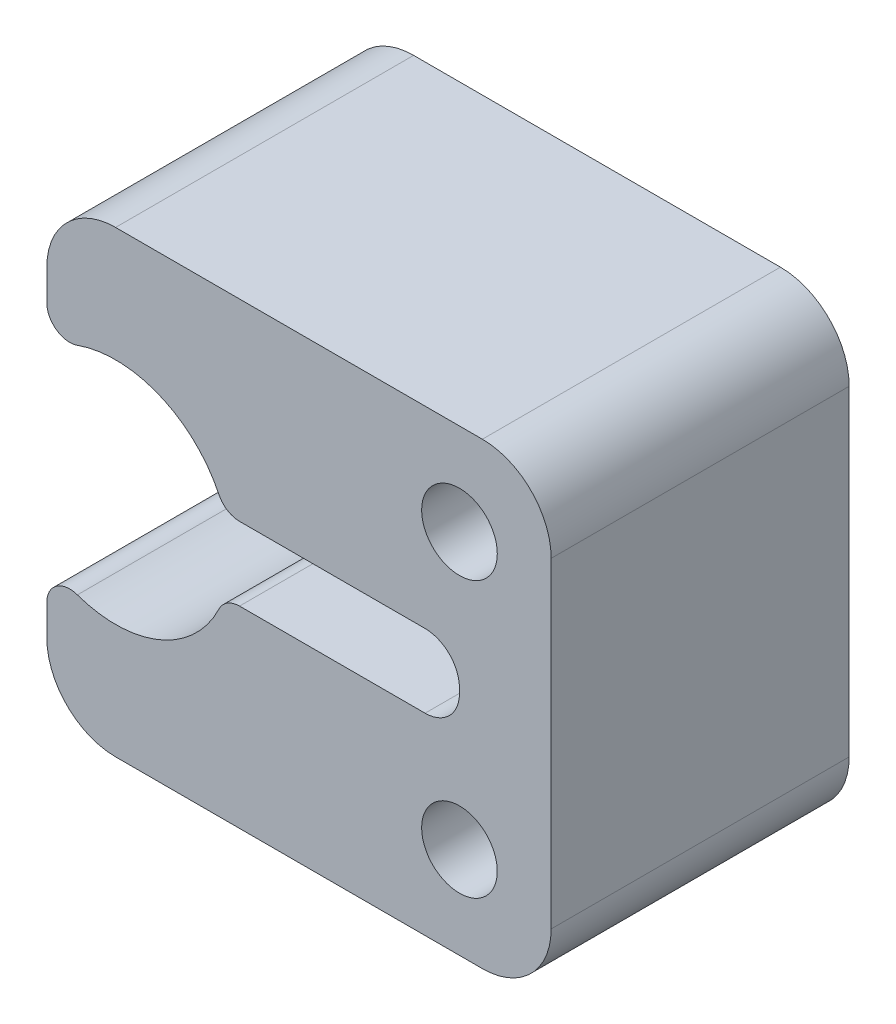
from build123d import *

# Parameters (mm, degrees)
ESQUISSE1_W                  = 22
ESQUISSE1_H                  = 20
BOSS_EXTRU_1_DEPTH           = 13
ESQUISSE2_R                  = 1.65
ENL_V_MAT_EXTRU_1_DEPTH      = 1
ENL_V_MAT_EXTRU_1_DEPTH_BACK = 14
ESQUISSE4_W                  = 12
ESQUISSE4_H                  = 3.2
ENL_V_MAT_EXTRU_2_DEPTH      = 13
CONG_1_R                     = 1
CONG_2_R                     = 3
CONG_3_R                     = 1.5


with BuildPart() as part:
    # Esquisse1 → Boss.-Extru.1 (new body)
    with BuildSketch(Plane.XY):
        with Locations((11, 10)):
            Rectangle(ESQUISSE1_W, ESQUISSE1_H)
    extrude(amount=BOSS_EXTRU_1_DEPTH)

    # Esquisse2 → Enlèv. mat.-Extru.1 (cut, two sides)
    with BuildSketch(Plane.XY.offset(13)) as enl_v_mat_extru_1_sk:
        with Locations((18, 16)):
            Circle(ESQUISSE2_R)
        with Locations((18, 4)):
            Circle(ESQUISSE2_R)
        with BuildLine():
            Line((0, 6), (0, 14))
            ThreePointArc((0, 14), (8, 10), (0, 6))
        make_face()
    extrude(amount=ENL_V_MAT_EXTRU_1_DEPTH, mode=Mode.SUBTRACT)
    extrude(enl_v_mat_extru_1_sk.sketch, amount=-ENL_V_MAT_EXTRU_1_DEPTH_BACK, mode=Mode.SUBTRACT)

    # Esquisse4 → Enlèv. mat.-Extru.2 (cut)
    with BuildSketch(Plane.XY.offset(13)):
        with Locations((12, 10)):
            Rectangle(ESQUISSE4_W, ESQUISSE4_H)
    extrude(amount=-ENL_V_MAT_EXTRU_2_DEPTH, mode=Mode.SUBTRACT)

    # Congé1
    cong_1_edges = [part.edges().sort_by_distance(p)[0] for p in [
        (0, 14, 6.5),
        (0, 6, 6.5),
        (7.737087713, 11.6, 6.5),
        (7.737087713, 8.4, 6.5),
    ]]
    fillet(cong_1_edges, radius=CONG_1_R)

    # Congé2
    cong_2_edges = [part.edges().sort_by_distance(p)[0] for p in [
        (0, 20, 6.5),
        (22, 20, 6.5),
        (22, 0, 6.5),
        (0, 0, 6.5),
    ]]
    fillet(cong_2_edges, radius=CONG_2_R)

    # Congé3
    cong_3_edges = [part.edges().sort_by_distance(p)[0] for p in [
        (18, 8.4, 6.5),
        (18, 11.6, 6.5),
    ]]
    fillet(cong_3_edges, radius=CONG_3_R)


solid = part.part
